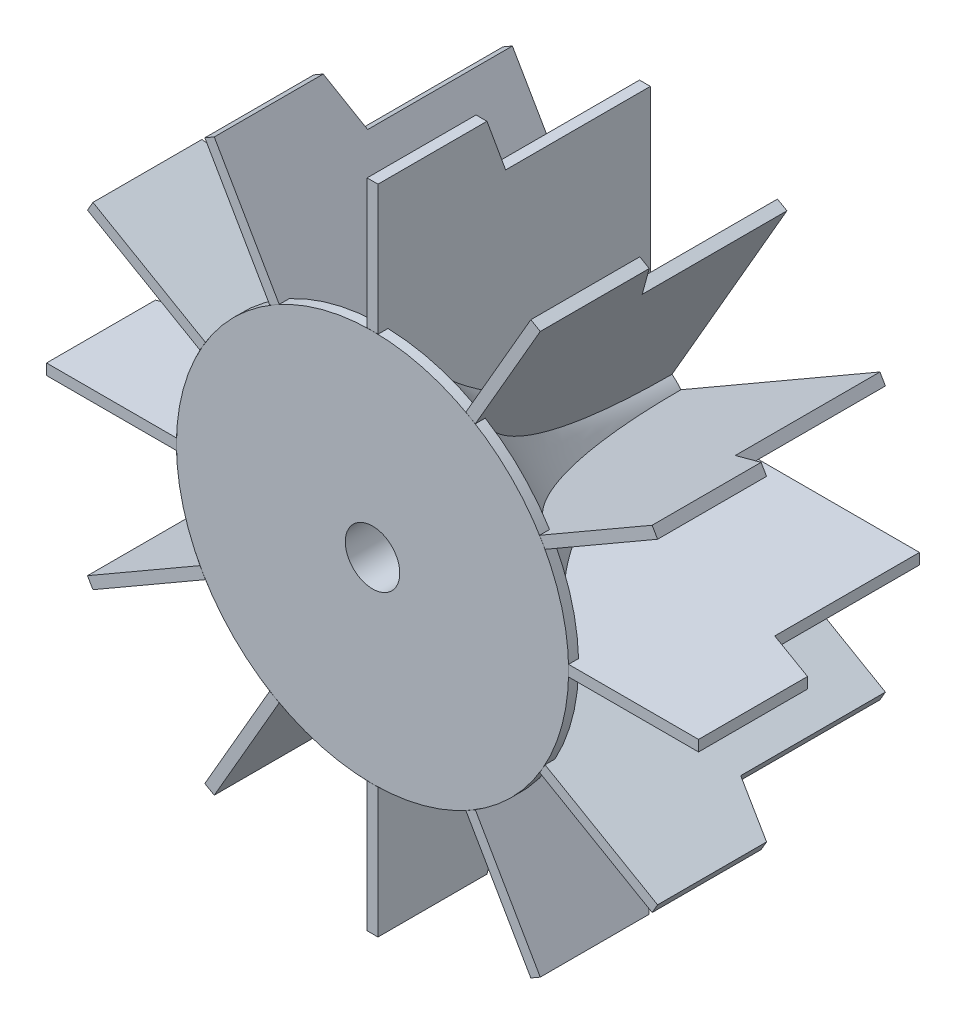
from build123d import *

# Parameters (mm, degrees)
SKETCH2_R           = 3.175
CUT_EXTRUDE1_DEPTH  = 32.75
BOSS_EXTRUDE1_DEPTH = 0.635
CIRPATTERN1_COUNT   = 12


with BuildPart() as part:
    # Sketch1 → Revolve1 (revolve)
    with BuildSketch(Plane(origin=(0, 0, 0), x_dir=(1, 0, 0), z_dir=(0, 1, 0))):
        with BuildLine():
            Line((0, 0), (22.86, 0))
            Line((22.86, 0), (22.86, 1.161858212))
            ThreePointArc((22.86, 1.161858212), (9.963717959, 14.101252807), (5.245270599, 31.75))
            Line((5.245270599, 31.75), (0, 31.75))
            Line((0, 31.75), (0, 0))
        make_face()
    revolve(axis=Axis((0, 0, -31.75), (0, 0, 1)))

    # Sketch2 → Cut-Extrude1 (cut, through all)
    with BuildSketch(Plane(origin=(0, 0, -31.75), x_dir=(-1, 0, 0), z_dir=(0, 0, -1))):
        Circle(SKETCH2_R)
    extrude(amount=-CUT_EXTRUDE1_DEPTH, mode=Mode.SUBTRACT)

    # Sketch4 → Boss-Extrude1 (add, symmetric)
    with BuildSketch(Plane(origin=(0, 0, 0), x_dir=(0, 0, -1), z_dir=(1, 0, 0))):
        Polygon((0, -38), (0, -22.86), (4.496537435, -6.200420248), (31.75, -4.781973466), (31.75, -32), (14.883821406, -32), (12.7, -38), align=None)
    boss_extrude1 = extrude(amount=BOSS_EXTRUDE1_DEPTH, both=True)

    # CirPattern1: Boss-Extrude1 ×12 about axis
    cirpattern1_axis = Axis((0, 0, 0), (0, 0, 1))
    for i in range(1, CIRPATTERN1_COUNT):
        add(boss_extrude1.rotate(cirpattern1_axis, i * 360 / CIRPATTERN1_COUNT))


solid = part.part
